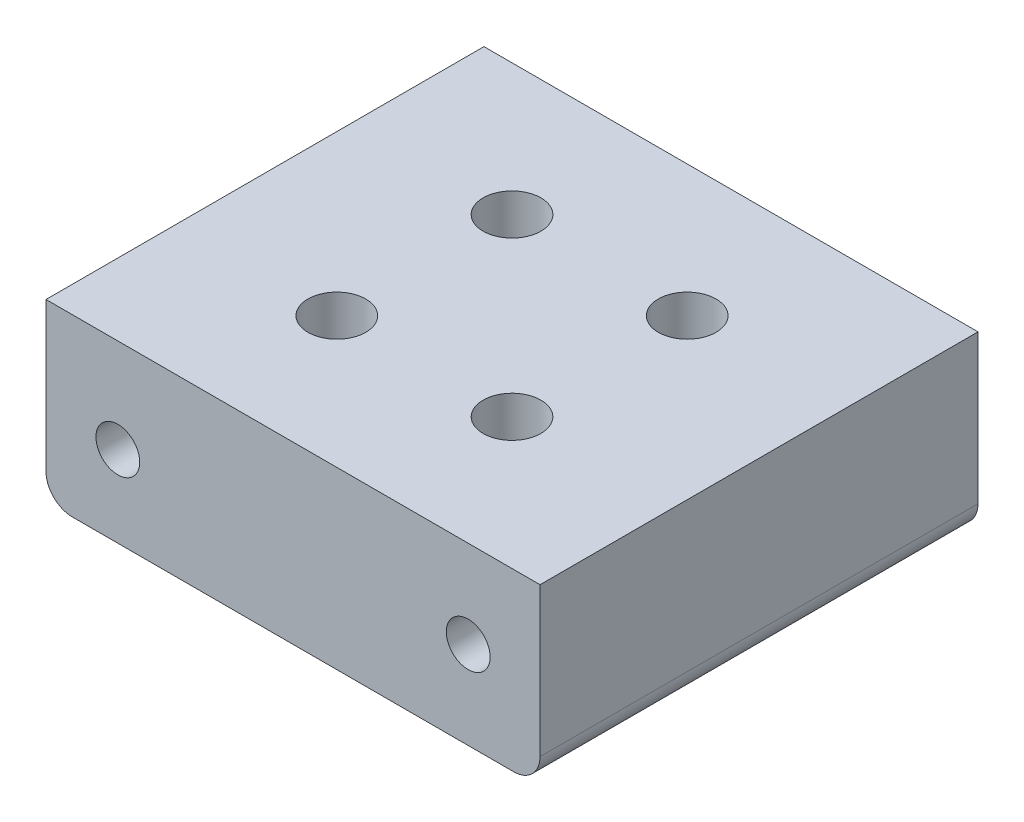
from build123d import *

# Parameters (mm, degrees)
BOSS_EXTRUDE1_DEPTH     = 50
TAP_DRILL_FOR_M6_TAP1_D = 5
M6_CLEARANCE_HOLE1_D    = 6.6


with BuildPart() as part:
    # Sketch1 → Boss-Extrude1 (new body)
    with BuildSketch(Plane.XY):
        with BuildLine():
            Line((28.2, -17.5), (-28.2, -17.5))
            Line((-28.2, -17.5), (-28.2, -34.5))
            ThreePointArc((-28.2, -34.5), (-27.321320344, -36.621320344), (-25.2, -37.5))
            Line((-25.2, -37.5), (25.2, -37.5))
            ThreePointArc((25.2, -37.5), (27.321320343, -36.621320344), (28.2, -34.5))
            Line((28.2, -34.5), (28.2, -17.5))
        make_face()
    extrude(amount=BOSS_EXTRUDE1_DEPTH)

    # Tap Drill for M6 Tap1 (through all)
    with Locations(Plane(origin=(0, 0, 0), x_dir=(-1, 0, 0), z_dir=(0, 0, -1))):
        with Locations((-20, -27.5), (20, -28.237657735)):
            Hole(TAP_DRILL_FOR_M6_TAP1_D / 2)

    # M6 Clearance Hole1 (through all)
    with Locations(Plane(origin=(0, -37.5, 0), x_dir=(-1, 0, 0), z_dir=(0, -1, 0))):
        with Locations((10, -15), (-10, -35), (10, -35), (-10, -15)):
            Hole(M6_CLEARANCE_HOLE1_D / 2)


solid = part.part
